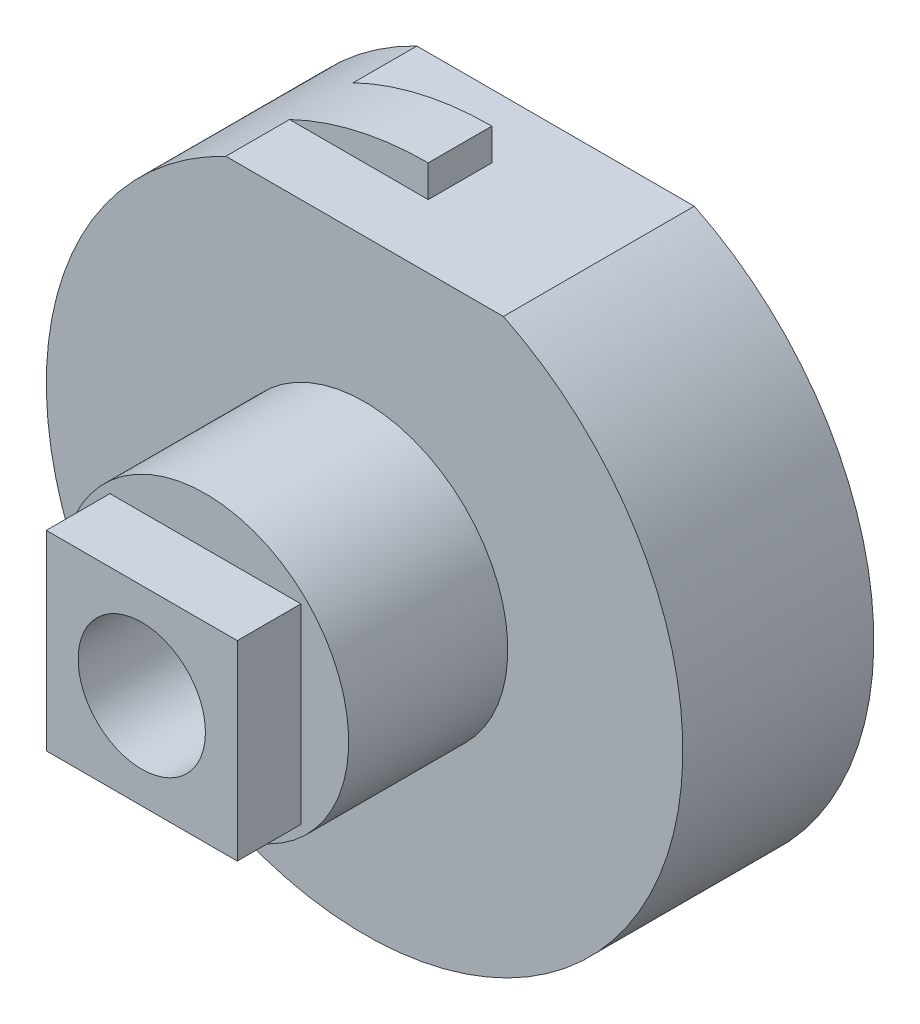
from build123d import *

# Parameters (mm, degrees)
CROQUIS1_W                           = 1.5
CROQUIS1_H                           = 1.5
SALIENTE_EXTRUIR1_DEPTH              = 0.5
CROQUIS2_R                           = 1.125
SALIENTE_EXTRUIR2_DEPTH              = 1.25
CROQUIS5_R                           = 2.5
SALIENTE_EXTRUIR5_DEPTH              = 1.5
CROQUIS6_R                           = 1.25
SALIENTE_EXTRUIR6_DEPTH              = 0.25
CROQUIS7_R                           = 0.5
SALIENTE_EXTRUIR7_DEPTH              = 0.5
CORTAR_EXTRUIR1_DEPTH                = 10
TALADRO_ROSCADO_M1X0_251_D           = 0.75
TALADRO_ROSCADO_M1X0_251_DEPTH       = 2.25
TALADRO_ROSCADO_M1X0_251_CBORE_D     = 1
TALADRO_ROSCADO_M1X0_251_CBORE_DEPTH = 2
TALADRO_ROSCADO_M1X0_251_TIP         = 0.225322732


with BuildPart() as part:
    # Croquis1 → Saliente-Extruir1 (new body)
    with BuildSketch(Plane.XY):
        Rectangle(CROQUIS1_W, CROQUIS1_H)
    extrude(amount=SALIENTE_EXTRUIR1_DEPTH)

    # Croquis2 → Saliente-Extruir2 (add)
    with BuildSketch(Plane(origin=(0, 0, 0), x_dir=(-1, 0, 0), z_dir=(0, 0, -1))):
        Circle(CROQUIS2_R)
    extrude(amount=SALIENTE_EXTRUIR2_DEPTH)

    # Croquis5 → Saliente-Extruir5 (add)
    with BuildSketch(Plane(origin=(0, 0, -1.25), x_dir=(-1, 0, 0), z_dir=(0, 0, -1))):
        Circle(CROQUIS5_R)
    extrude(amount=SALIENTE_EXTRUIR5_DEPTH)

    # Croquis6 → Saliente-Extruir6 (add)
    with BuildSketch(Plane(origin=(0, 0, -2.75), x_dir=(-1, 0, 0), z_dir=(0, 0, -1))):
        Circle(CROQUIS6_R)
    extrude(amount=SALIENTE_EXTRUIR6_DEPTH)

    # Croquis7 → Saliente-Extruir7 (add)
    with BuildSketch(Plane(origin=(0, 0, -3), x_dir=(-1, 0, 0), z_dir=(0, 0, -1))):
        Circle(CROQUIS7_R)
    extrude(amount=SALIENTE_EXTRUIR7_DEPTH)

    # Croquis11 → Cortar-Extruir1 (cut)
    with BuildSketch(Plane(origin=(0, 2.25, 0), x_dir=(-1, 0, 0), z_dir=(0, 1, 0))):
        Polygon((-1.5, -1.25), (1.5, -1.25), (1.5, -1.75), (0, -1.75), (0, -2.25), (1.5, -2.25), (1.5, -2.75), (-1.5, -2.75), align=None)
    extrude(amount=CORTAR_EXTRUIR1_DEPTH, mode=Mode.SUBTRACT)

    # Taladro roscado M1x0.251
    with Locations(Plane.XY.offset(0.5)):
        with Locations((0, 0)):
            CounterBoreHole(TALADRO_ROSCADO_M1X0_251_D / 2, TALADRO_ROSCADO_M1X0_251_CBORE_D / 2, TALADRO_ROSCADO_M1X0_251_CBORE_DEPTH, depth=TALADRO_ROSCADO_M1X0_251_DEPTH)
            with Locations((0, 0, -(TALADRO_ROSCADO_M1X0_251_DEPTH + TALADRO_ROSCADO_M1X0_251_TIP / 2))):  # 118° drill point
                Cone(0, TALADRO_ROSCADO_M1X0_251_D / 2, TALADRO_ROSCADO_M1X0_251_TIP, mode=Mode.SUBTRACT)


solid = part.part
